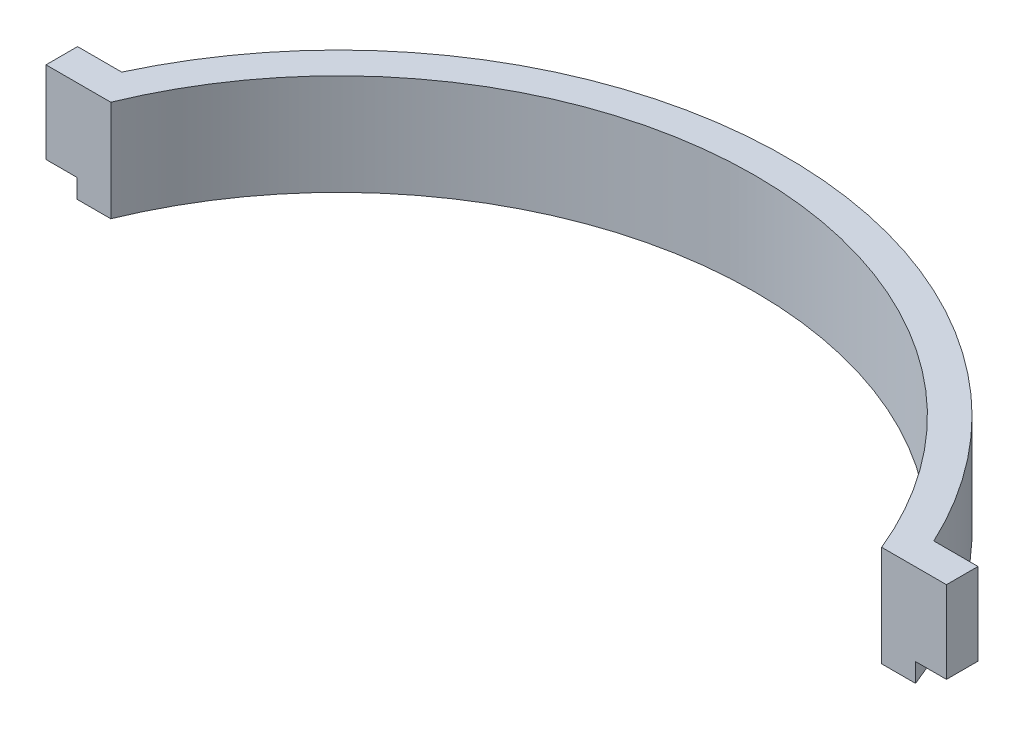
from build123d import *

# Parameters (mm, degrees)
BOSS_EXTRUDE1_DEPTH = 13
BOSS_EXTRUDE2_DEPTH = 3


with BuildPart() as part:
    # Sketch2 → Boss-Extrude1 (new body)
    with BuildSketch(Plane(origin=(0, 0, 0), x_dir=(1, 0, 0), z_dir=(0, 1, 0))):
        with BuildLine():
            Line((-71.350602173, 25), (-61.081912216, 25))
            ThreePointArc((-61.081912216, 25), (0, 66), (61.081912216, 25))
            Line((61.081912216, 25), (71.350602173, 25))
            Line((71.350602173, 25), (71.350602173, 30))
            Line((71.350602173, 30), (64.350602173, 30))
            ThreePointArc((64.350602173, 30), (0, 71), (-64.350602173, 30))
            Line((-64.350602173, 30), (-71.350602173, 30))
            Line((-71.350602173, 30), (-71.350602173, 25))
        make_face()
    extrude(amount=BOSS_EXTRUDE1_DEPTH)

    # Sketch3 → Boss-Extrude2 (add)
    with BuildSketch(Plane.XZ):
        with BuildLine():
            Line((66.452990903, -25), (61.081912216, -25))
            ThreePointArc((61.081912216, -25), (0, -66), (-61.081912216, -25))
            Line((-61.081912216, -25), (-66.452990903, -25))
            ThreePointArc((-66.452990903, -25), (0, -71), (66.452990903, -25))
        make_face()
    extrude(amount=BOSS_EXTRUDE2_DEPTH)


solid = part.part
